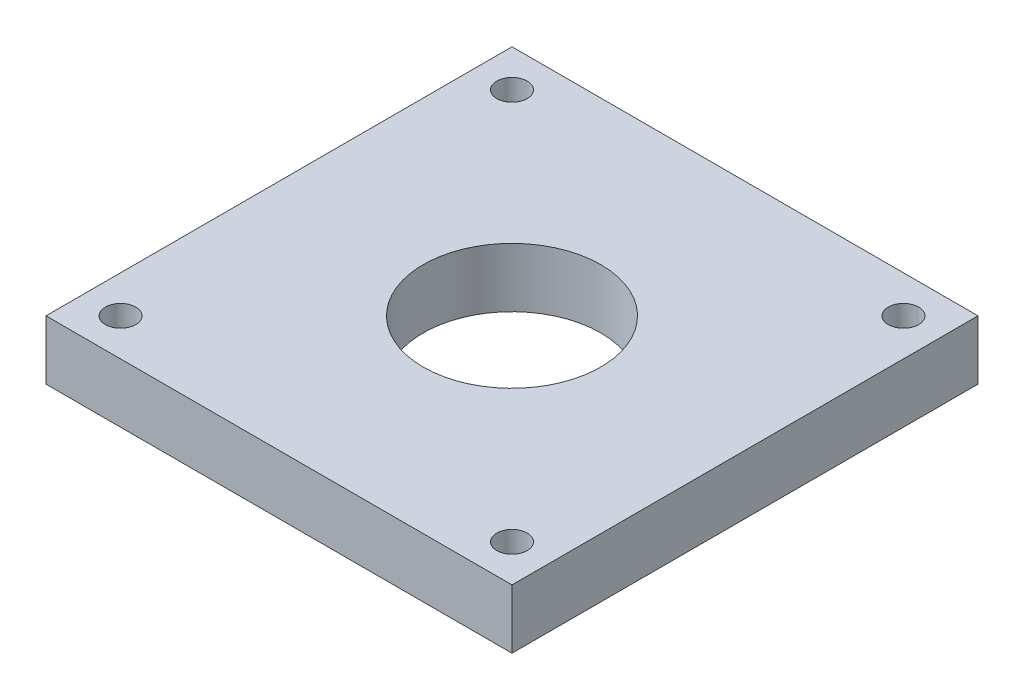
from build123d import *

# Parameters (mm, degrees)
SKETCH2_W             = 50
SKETCH2_H             = 50
SKETCH2_R             = 9.525
BOSS_EXTRUDE1_DEPTH   = 6.35
F_4_CLEARANCE_HOLE1_D = 3.2639


with BuildPart() as part:
    # Sketch2 → Boss-Extrude1 (new body)
    with BuildSketch(Plane(origin=(0, 0, 0), x_dir=(1, 0, 0), z_dir=(0, 1, 0))):
        Rectangle(SKETCH2_W, SKETCH2_H)
        Circle(SKETCH2_R, mode=Mode.SUBTRACT)
    extrude(amount=BOSS_EXTRUDE1_DEPTH)

    # #4 Clearance Hole1 (through all)
    with Locations(Plane(origin=(0, 6.35, 0), x_dir=(1, 0, 0), z_dir=(0, 1, 0))):
        with Locations((-21, -21), (21, -21), (21, 21), (-21, 21)):
            Hole(F_4_CLEARANCE_HOLE1_D / 2)


solid = part.part
